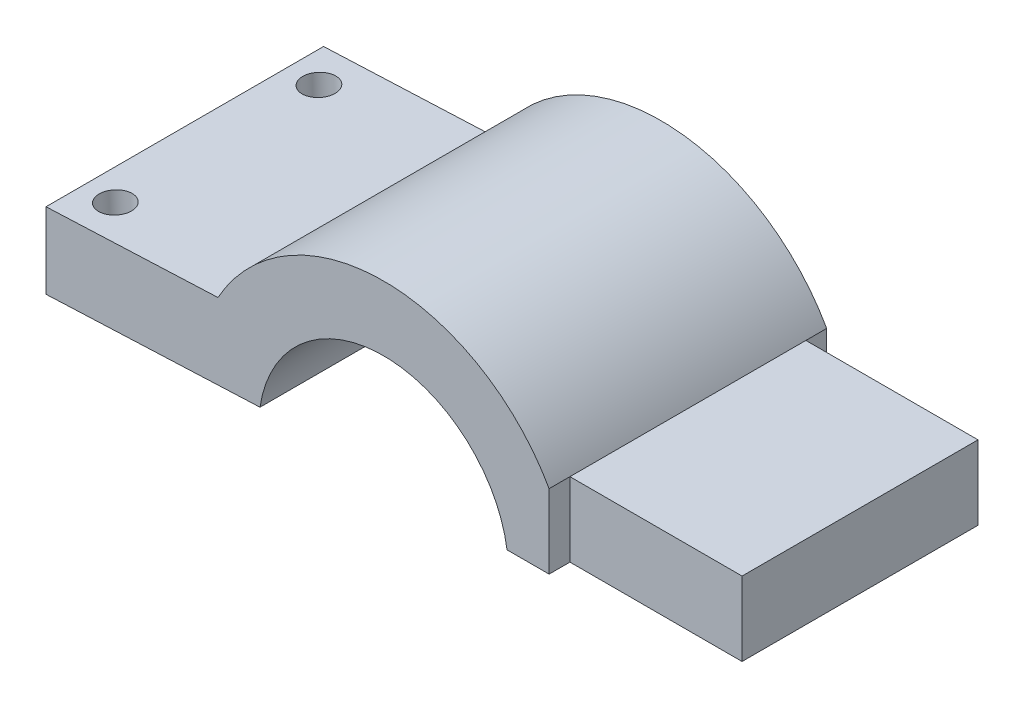
from build123d import *

# Parameters (mm, degrees)
SALIENTE_EXTRUIR1_DEPTH = 30
CORTAR_EXTRUIR1_DEPTH   = 10
CROQUIS4_R              = 1.75
CORTAR_EXTRUIR2_DEPTH   = 10


with BuildPart() as part:
    # Croquis1 → Saliente-Extruir1 (new body)
    with BuildSketch(Plane.XY):
        with BuildLine():
            Line((26.421334586, 0), (26.421334586, 8))
            Line((26.421334586, 8), (7.816864755, 8))
            ThreePointArc((7.816864755, 8), (-10.078665414, 18.5), (-27.974195582, 8))
            Line((-27.974195582, 8), (-46.558360995, 7.201596348))
            Line((-46.558360995, 7.201596348), (-46.558360995, -0.993642206))
            Line((-46.558360995, -0.993642206), (-23.429695336, 0))
            ThreePointArc((-23.429695336, 0), (-10.078665414, 11.5), (3.272364509, 0))
            Line((3.272364509, 0), (26.421334586, 0))
        make_face()
    extrude(amount=SALIENTE_EXTRUIR1_DEPTH)

    # Croquis3 → Cortar-Extruir1 (cut)
    with BuildSketch(Plane(origin=(0, 8, 0), x_dir=(1, 0, 0), z_dir=(0, 1, 0))):
        Polygon((26.421334586, -2.25), (26.421334586, -27.75), (7.816864755, -27.75), (7.816864755, -33.359079395), (34.243736359, -33.359079395), (34.243736359, 4.857090857), (7.816864755, 4.857090857), (7.816864755, -2.25), align=None)
    extrude(amount=-CORTAR_EXTRUIR1_DEPTH, mode=Mode.SUBTRACT)

    # Croquis4 → Cortar-Extruir2 (cut)
    with BuildSketch(Plane(origin=(-0.394595422, 9.184861036, 0), x_dir=(0.99907843, 0.04292191, 0), z_dir=(-0.04292191, 0.99907843, 0))):
        with Locations((-42.706347949, -26)):
            Circle(CROQUIS4_R)
        with Locations((-42.706347949, -4)):
            Circle(CROQUIS4_R)
    extrude(amount=-CORTAR_EXTRUIR2_DEPTH, mode=Mode.SUBTRACT)


solid = part.part
